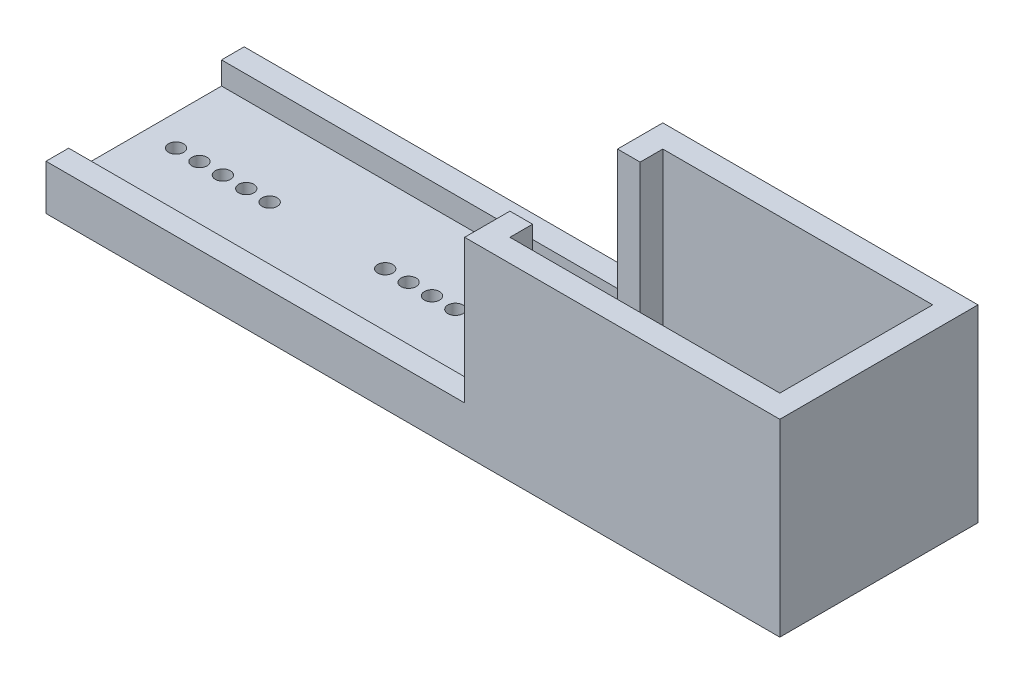
from build123d import *

# Parameters (mm, degrees)
SKETCH1_W           = 97.2
SKETCH1_H           = 26.25
BOSS_EXTRUDE1_DEPTH = 3
BOSS_EXTRUDE2_DEPTH = 22
SKETCH3_W           = 6.5
SKETCH3_H           = 20.25
CUT_EXTRUDE1_DEPTH  = 4
SKETCH5_R           = 1
CUT_EXTRUDE2_DEPTH  = 4
SKETCH6_W           = 55.45
SKETCH6_H           = 3
BOSS_EXTRUDE3_DEPTH = 3


with BuildPart() as part:
    # Sketch1 → Boss-Extrude1 (new body)
    with BuildSketch(Plane(origin=(0, 0, 0), x_dir=(1, 0, 0), z_dir=(0, 1, 0))):
        Rectangle(SKETCH1_W, SKETCH1_H)
    extrude(amount=BOSS_EXTRUDE1_DEPTH)

    # Sketch2 → Boss-Extrude2 (add)
    with BuildSketch(Plane(origin=(0, 3, 0), x_dir=(1, 0, 0), z_dir=(0, 1, 0))):
        Polygon((48.6, -13.125), (9.85, -13.125), (6.85, -13.125), (6.85, -7.125), (9.85, -7.125), (9.85, -10.125), (45.6, -10.125), (45.6, 10.125), (9.85, 10.125), (9.85, 7.125), (6.85, 7.125), (6.85, 13.125), (9.6, 13.125), (45.6, 13.125), (48.6, 13.125), align=None)
    extrude(amount=BOSS_EXTRUDE2_DEPTH)

    # Sketch3 → Cut-Extrude1 (cut, through all)
    with BuildSketch(Plane(origin=(0, 3, 0), x_dir=(1, 0, 0), z_dir=(0, 1, 0))):
        with Locations((17.6, 0)):
            Rectangle(SKETCH3_W, SKETCH3_H)
    extrude(amount=-CUT_EXTRUDE1_DEPTH, mode=Mode.SUBTRACT)

    # Sketch5 → Cut-Extrude2 (cut, through all)
    with BuildSketch(Plane(origin=(0, 3, 0), x_dir=(1, 0, 0), z_dir=(0, 1, 0))):
        with Locations((-32.1, 0)):
            Circle(SKETCH5_R)
        with Locations((-16.8, 0)):
            Circle(SKETCH5_R)
        with Locations((-13.7, 0)):
            Circle(SKETCH5_R)
        with Locations((-10.6, 0)):
            Circle(SKETCH5_R)
        with Locations((-7.5, 0)):
            Circle(SKETCH5_R)
        with Locations((-4.4, 0)):
            Circle(SKETCH5_R)
        with Locations((-35.2, 0)):
            Circle(SKETCH5_R)
        with Locations((-38.3, 0)):
            Circle(SKETCH5_R)
        with Locations((-41.4, 0)):
            Circle(SKETCH5_R)
        with Locations((-44.5, 0)):
            Circle(SKETCH5_R)
    extrude(amount=-CUT_EXTRUDE2_DEPTH, mode=Mode.SUBTRACT)

    # Sketch6 → Boss-Extrude3 (add)
    with BuildSketch(Plane(origin=(0, 3, 0), x_dir=(1, 0, 0), z_dir=(0, 1, 0))):
        with Locations((-20.875, 11.625)):
            Rectangle(SKETCH6_W, SKETCH6_H)
        with Locations((-20.875, -11.625)):
            Rectangle(SKETCH6_W, SKETCH6_H)
    extrude(amount=BOSS_EXTRUDE3_DEPTH)


solid = part.part
